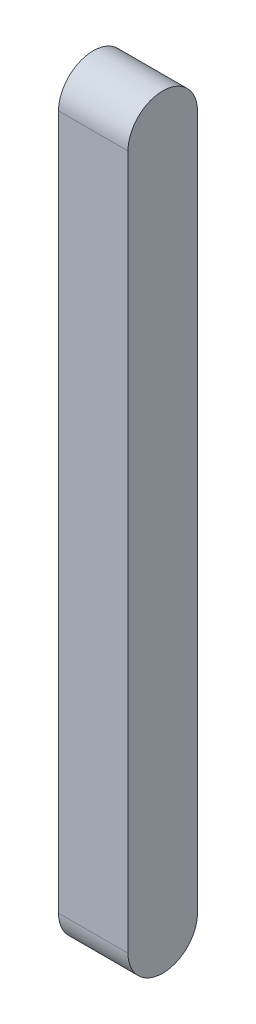
from build123d import *

# Parameters (mm, degrees)
EXTRUDE_1_DEPTH = 10


with BuildPart() as part:
    # 草图1 → 凸台-拉伸1 (new body)
    with BuildSketch(Plane(origin=(56.720720721, 0, 0), x_dir=(0, 0, -1), z_dir=(1, 0, 0))):
        with BuildLine():
            Line((-45.396141561, -21.572007284), (-45.396141561, -121.572007284))
            ThreePointArc((-45.396141561, -121.572007284), (-50.396141561, -126.572007284), (-55.396141561, -121.572007284))
            Line((-55.396141561, -121.572007284), (-55.396141561, -21.572007284))
            ThreePointArc((-55.396141561, -21.572007284), (-50.396141561, -16.572007284), (-45.396141561, -21.572007284))
        make_face()
    extrude(amount=EXTRUDE_1_DEPTH)


solid = part.part
